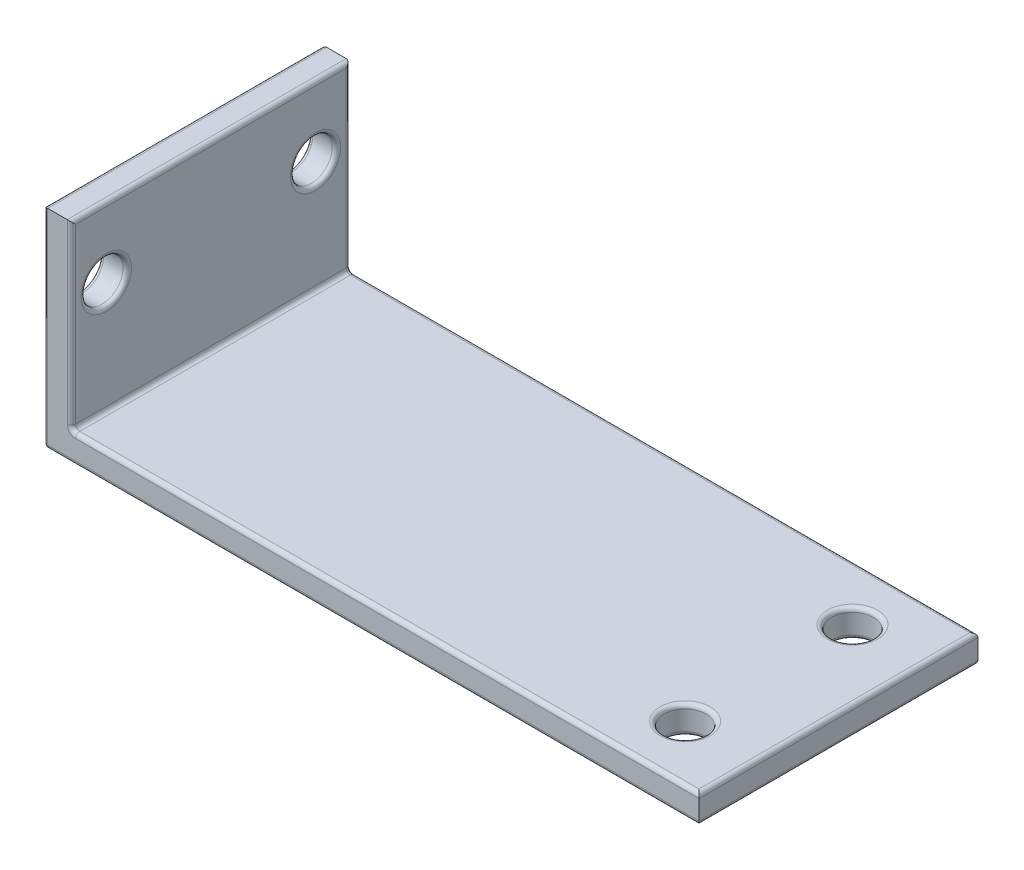
from build123d import *

# Parameters (mm, degrees)
BOSS_EXTRUDE1_DEPTH = 10
SKETCH2_R           = 1.5
CUT_EXTRUDE1_DEPTH  = 48
SKETCH3_R           = 1.5
CUT_EXTRUDE2_DEPTH  = 16
FILLET1_R           = 0.3


with BuildPart() as part:
    # Sketch1 → Boss-Extrude1 (new body, symmetric)
    with BuildSketch(Plane.XY):
        Polygon((0, 0), (47, 0), (47, 2), (2, 2), (2, 15), (0, 15), align=None)
    extrude(amount=BOSS_EXTRUDE1_DEPTH, both=True)

    # Sketch2 → Cut-Extrude1 (cut, through all)
    with BuildSketch(Plane.ZY):
        with Locations((7.5, 10)):
            Circle(SKETCH2_R)
        with Locations((-7.5, 10)):
            Circle(SKETCH2_R)
    extrude(amount=-CUT_EXTRUDE1_DEPTH, mode=Mode.SUBTRACT)

    # Sketch3 → Cut-Extrude2 (cut, through all)
    with BuildSketch(Plane.XZ):
        with Locations((42, 6)):
            Circle(SKETCH3_R)
        with Locations((42, -6)):
            Circle(SKETCH3_R)
    extrude(amount=-CUT_EXTRUDE2_DEPTH, mode=Mode.SUBTRACT)

    # Fillet1
    fillet1_edges = [part.edges().sort_by_distance(p)[0] for p in [
        (0, 15, 0),
        (2, 15, 0),
        (2, 2, 0),
        (47, 2, 0),
        (47, 0, 0),
        (0, 0, 0),
        (24.5, 2, 10),
        (2, 8.5, 10),
        (2, 10, 6),
        (0, 10, 6),
        (2, 10, -9),
        (0, 10, -9),
        (40.5, 2, 6),
        (40.5, 0, 6),
        (40.5, 2, -6),
        (40.5, 0, -6),
        (0, 7.5, 10),
        (2, 8.5, -10),
        (24.5, 2, -10),
        (23.5, 0, -10),
        (0, 7.5, -10),
        (23.5, 0, 10),
    ]]
    fillet(fillet1_edges, radius=FILLET1_R)


solid = part.part
